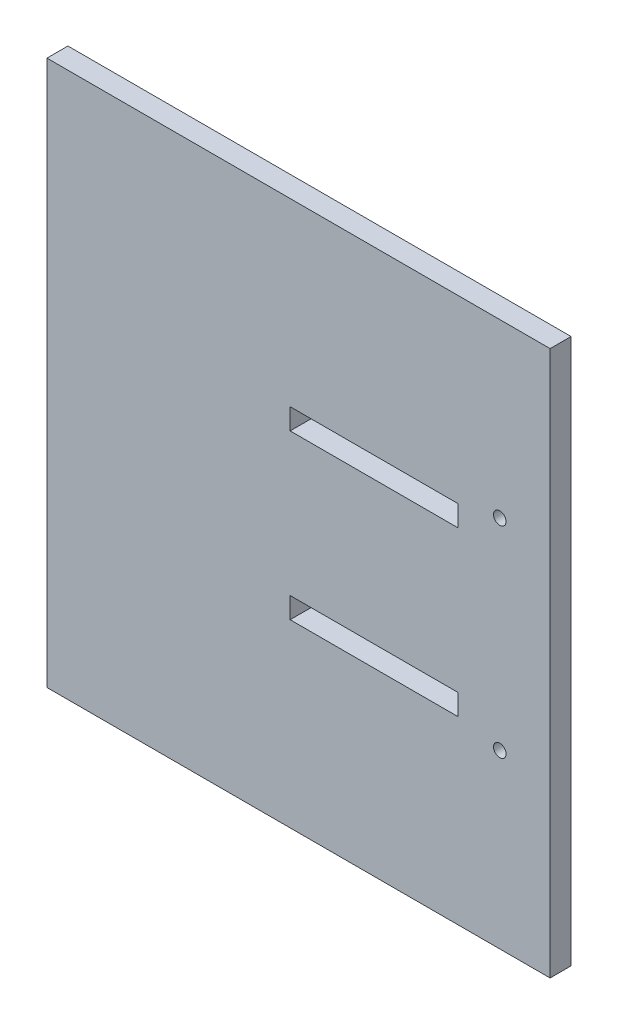
from build123d import *

# Parameters (mm, degrees)
SKETCH2_W           = 120
SKETCH2_H           = 130
BOSS_EXTRUDE1_DEPTH = 5
SKETCH3_R           = 1.5
SKETCH3_W           = 40
SKETCH3_H           = 5
CUT_EXTRUDE1_DEPTH  = 6


with BuildPart() as part:
    # Sketch2 → Boss-Extrude1 (new body)
    with BuildSketch(Plane.XY):
        Rectangle(SKETCH2_W, SKETCH2_H)
    extrude(amount=BOSS_EXTRUDE1_DEPTH)

    # Sketch3 → Cut-Extrude1 (cut, through all)
    with BuildSketch(Plane.XY):
        with Locations((48, 24)):
            Circle(SKETCH3_R)
        with Locations((48, -24)):
            Circle(SKETCH3_R)
        with Locations((18, 19.5)):
            Rectangle(SKETCH3_W, SKETCH3_H)
        with Locations((18, -19.5)):
            Rectangle(SKETCH3_W, SKETCH3_H)
    extrude(amount=CUT_EXTRUDE1_DEPTH, mode=Mode.SUBTRACT)


solid = part.part
